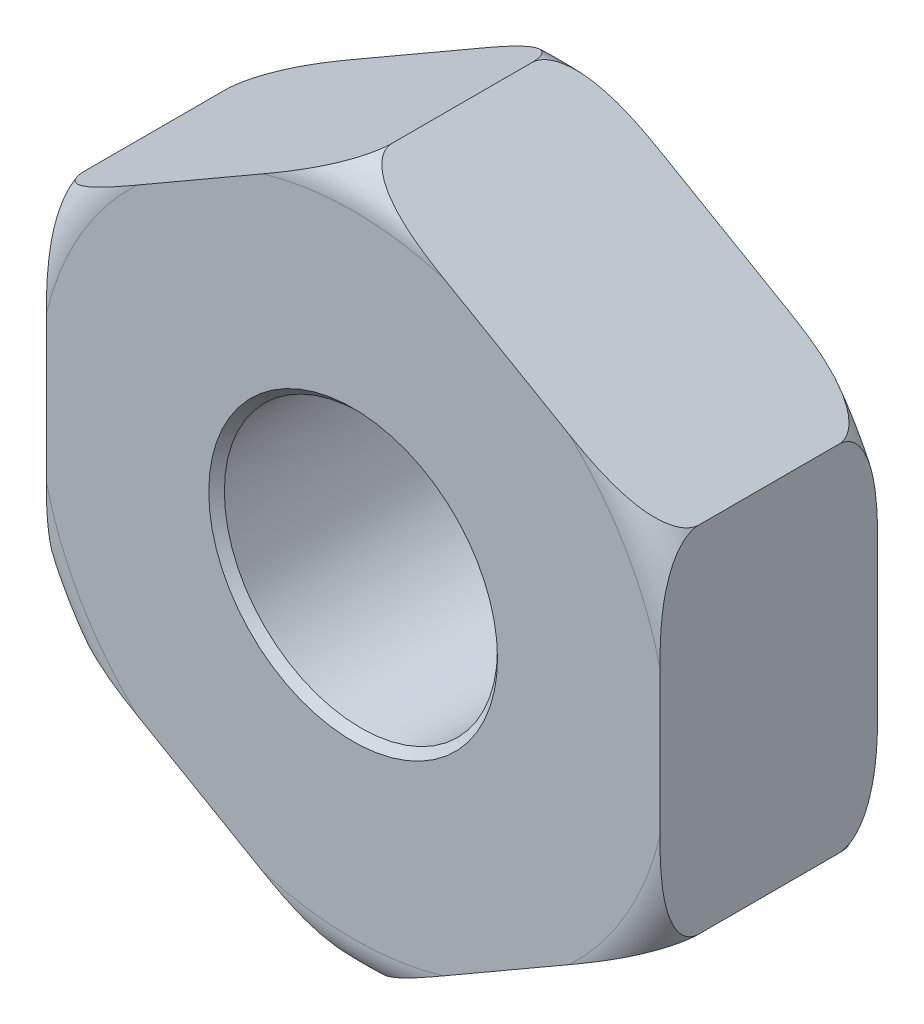
from build123d import *

# Parameters (mm, degrees)
SKETCH1_R          = 1.7525
BASE_EXTRUDE_DEPTH = 1.397


with BuildPart() as part:
    # Sketch1 → Base-Extrude (new body, symmetric)
    with BuildSketch(Plane.XY):
        Polygon((0, 4.54605602), (-3.937, 2.27302801), (-3.937, -2.27302801), (0, -4.54605602), (3.937, -2.27302801), (3.937, 2.27302801), align=None)
        Circle(SKETCH1_R, mode=Mode.SUBTRACT)
    extrude(amount=BASE_EXTRUDE_DEPTH, both=True)

    # Sketch2 → DetailCut (revolve, cut)
    with BuildSketch(Plane(origin=(0, 0, 0), x_dir=(0, 0, -1), z_dir=(1, 0, 0))):
        Polygon((-1.397, 1.7525), (-1.397, 1.8525), (-1.297, 1.7525), align=None)
        with BuildLine():
            Line((-1.397, 4.54605602), (-1.397, 4.04605602))
            ThreePointArc((-1.397, 4.04605602), (-1.250553391, 4.39960941), (-0.897, 4.54605602))
            Line((-0.897, 4.54605602), (-1.397, 4.54605602))
        make_face()
        with BuildLine():
            Line((1.397, 4.54605602), (0.897, 4.54605602))
            ThreePointArc((0.897, 4.54605602), (1.250553391, 4.39960941), (1.397, 4.04605602))
            Line((1.397, 4.04605602), (1.397, 4.54605602))
        make_face()
        Polygon((1.297, 1.7525), (1.397, 1.7525), (1.397, 1.8525), align=None)
    revolve(axis=Axis((0, 0, 0), (0, 0, -1)), mode=Mode.SUBTRACT)


solid = part.part
